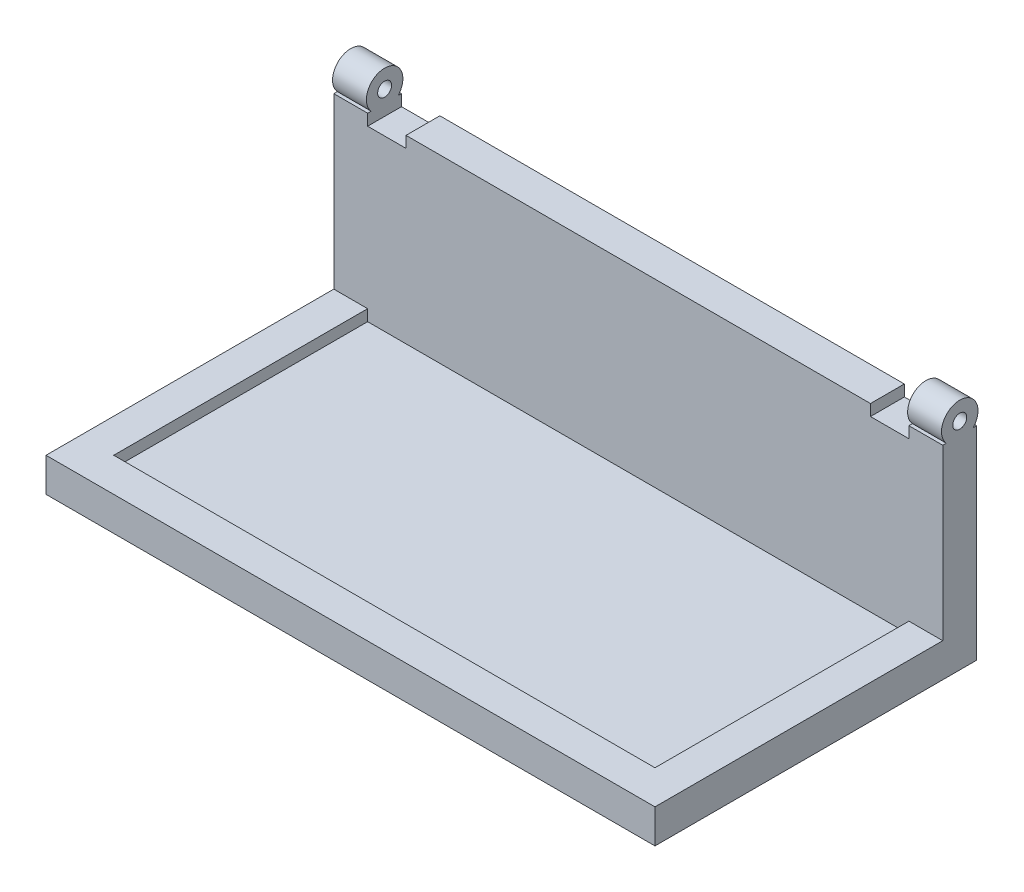
from build123d import *

# Parameters (mm, degrees)
SKETCH1_W           = 269.8
SKETCH1_H           = 142.5
BOSS_EXTRUDE2_DEPTH = 15
SKETCH2_W           = 239.8
SKETCH2_H           = 112.5
CUT_EXTRUDE1_DEPTH  = 5
BOSS_EXTRUDE3_DEPTH = 75
SKETCH7_R           = 8.089056034
SKETCH7_R_2         = 3.089056034
BOSS_EXTRUDE4_DEPTH = 15
SKETCH12_R          = 8.089056034
SKETCH12_R_2        = 3.089056034
BOSS_EXTRUDE5_DEPTH = 15
SKETCH14_W          = 17.02273013
SKETCH14_H          = 15
CUT_EXTRUDE2_DEPTH  = 5


with BuildPart() as part:
    # Sketch1 → Boss-Extrude2 (new body)
    with BuildSketch(Plane(origin=(0, 0, 0), x_dir=(1, 0, 0), z_dir=(0, 1, 0))):
        with Locations((-23.308401977, 12.292504119)):
            Rectangle(SKETCH1_W, SKETCH1_H)
    extrude(amount=BOSS_EXTRUDE2_DEPTH)

    # Sketch2 → Cut-Extrude1 (cut)
    with BuildSketch(Plane(origin=(0, 15, 0), x_dir=(1, 0, 0), z_dir=(0, 1, 0))):
        with Locations((-23.308401977, 12.292504119)):
            Rectangle(SKETCH2_W, SKETCH2_H)
    extrude(amount=-CUT_EXTRUDE1_DEPTH, mode=Mode.SUBTRACT)

    # Sketch3 → Boss-Extrude3 (add)
    with BuildSketch(Plane(origin=(0, 15, 0), x_dir=(1, 0, 0), z_dir=(0, 1, 0))):
        Polygon((-143.208401977, 68.542504119), (-158.208401977, 68.542504119), (-158.208401977, 83.542504119), (111.591598023, 83.542504119), (111.591598023, 68.542504119), align=None)
    extrude(amount=BOSS_EXTRUDE3_DEPTH)

    # Sketch7 → Boss-Extrude4 (add)
    with BuildSketch(Plane(origin=(-143.208401977, 0, 0), x_dir=(0, 0, -1), z_dir=(1, 0, 0))):
        with Locations((76.070987498, 95.45383679)):
            Circle(SKETCH7_R)
        with Locations((76.070987498, 95.45383679)):
            Circle(SKETCH7_R_2, mode=Mode.SUBTRACT)
    extrude(amount=-BOSS_EXTRUDE4_DEPTH)

    # Sketch12 → Boss-Extrude5 (add)
    with BuildSketch(Plane.ZY.offset(-96.591598023)):
        with Locations((-76.070987498, 95.45383679)):
            Circle(SKETCH12_R)
        with Locations((-76.070987498, 95.45383679)):
            Circle(SKETCH12_R_2, mode=Mode.SUBTRACT)
    extrude(amount=-BOSS_EXTRUDE5_DEPTH)

    # Sketch14 → Cut-Extrude2 (cut)
    with BuildSketch(Plane(origin=(0, 90, 0), x_dir=(1, 0, 0), z_dir=(0, 1, 0))):
        Polygon((-126.208401977, 83.542504119), (-128.208401977, 83.542504119), (-143.208401977, 83.542504119), (-143.208401977, 82.044972081), (-143.208401977, 70.097002915), (-143.208401977, 68.542504119), (-128.208401977, 68.542504119), (-126.208401977, 68.542504119), align=None)
        with Locations((88.080232958, 76.042504119)):
            Rectangle(SKETCH14_W, SKETCH14_H)
    extrude(amount=-CUT_EXTRUDE2_DEPTH, mode=Mode.SUBTRACT)


solid = part.part
